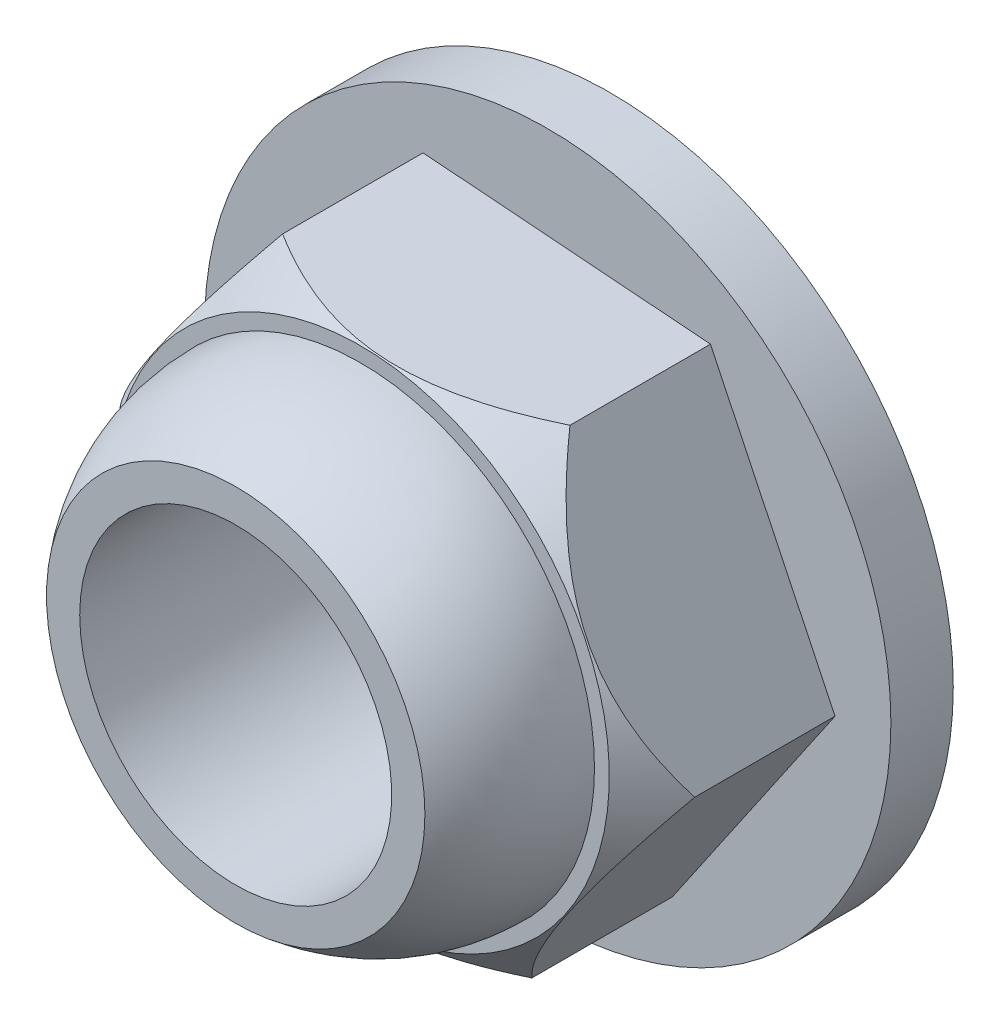
from build123d import *

# Parameters (mm, degrees)
SKETCH_1_R          = 5.5
EXTRUDE_1_DEPTH     = 1
EXTRUDE_2_DEPTH     = 3
CUT_EXTRUDE_2_REACH = 8
SKETCH_9_R          = 2.5
CHAMFER_1_SIZE      = 0.3


with BuildPart() as part:
    # Эскиз1 → Бобышка-Вытянуть1 (new body)
    with BuildSketch(Plane.XY):
        Circle(SKETCH_1_R)
    extrude(amount=EXTRUDE_1_DEPTH)

    # Эскиз3 → Бобышка-Вытянуть2 (add)
    with BuildSketch(Plane.XY.offset(1)):
        Polygon((2.608163285, 3.811930956), (-1.997147402, 4.16470114), (-4.605310688, 0.352770185), (-2.608163285, -3.811930956), (1.997147402, -4.16470114), (4.605310688, -0.352770185), align=None)
    extrude(amount=EXTRUDE_2_DEPTH)

    # Эскиз5 → Вырез-Повернуть3 (revolve, cut)
    with BuildSketch(Plane(origin=(0, 0, 0), x_dir=(-0.997079012, 0.076376985, 0), z_dir=(-0.076376985, -0.997079012, 0))):
        Polygon((-4.618802154, -3.251492454), (-4.618802154, -4), (-3.987599163, -4), align=None)
    revolve(axis=Axis((0, 0, 0), (0, 0, 1)), mode=Mode.SUBTRACT)

    # Эскиз6 → Повернуть1 (revolve)
    with BuildSketch(Plane(origin=(0, 0, 0), x_dir=(0, 0, -1), z_dir=(1, 0, 0))):
        with BuildLine():
            Line((-4, 0), (-4, 3.75))
            ThreePointArc((-4, 3.75), (-5.062452688, 3.565118621), (-6, 3.032209738))
            Line((-6, 3.032209738), (-6, 0))
            Line((-6, 0), (-4, 0))
        make_face()
    revolve(axis=Axis((0, 0, 0.929807333), (0, 0, -1)))

    # Эскиз9 → Вырез-Вытянуть2 (cut, up to next)
    with BuildSketch(Plane(origin=(0, 0, 0), x_dir=(-1, 0, 0), z_dir=(0, 0, -1)), mode=Mode.PRIVATE) as cut_extrude_2_sk1:
        Circle(SKETCH_9_R)
    cut_extrude_2_tool1 = extrude(cut_extrude_2_sk1.sketch, amount=-CUT_EXTRUDE_2_REACH, mode=Mode.PRIVATE) & part.part
    add(cut_extrude_2_tool1.solids().sort_by_distance((0, 0, 0))[0], mode=Mode.SUBTRACT)

    # Фаска1
    chamfer_1_edges = [part.edges().sort_by_distance(p)[0] for p in [
        (2.5, 0, 0),
    ]]
    chamfer(chamfer_1_edges, length=CHAMFER_1_SIZE)


solid = part.part
